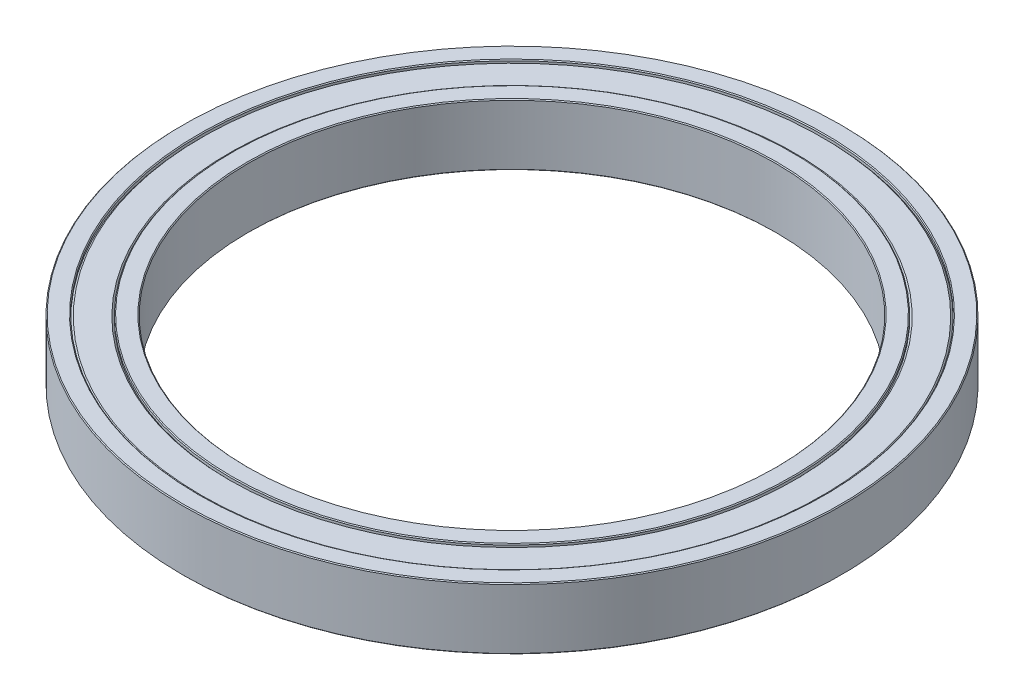
from build123d import *

# Parameters (mm, degrees)
SKETCH1_W     = 7.5
SKETCH1_H     = 7
CHAMFER1_SIZE = 0.1


with BuildPart() as part:
    # Sketch1 → Revolve1 (revolve)
    with BuildSketch(Plane(origin=(0, 0, 0), x_dir=(0, 0, -1), z_dir=(1, 0, 0))):
        with Locations((33.75, 0)):
            Rectangle(SKETCH1_W, SKETCH1_H)
    revolve(axis=Axis((0, 3.5, 0), (0, -1, 0)))

    # Sketch3 → Cut-Revolve2 (revolve, cut)
    with BuildSketch(Plane(origin=(0, 0, 0), x_dir=(0, 0, -1), z_dir=(1, 0, 0))):
        Polygon((35.3, 3.3), (35.5, 3.1), (35.5, 3.5), (32, 3.5), (32, 3.1), (32.2, 3.3), align=None)
    cut_revolve2 = revolve(axis=Axis((0, 3.5, 0), (0, -1, 0)), mode=Mode.SUBTRACT)

    # Mirror1: Cut-Revolve2 across plane
    add(cut_revolve2.mirror(Plane.ZX), mode=Mode.SUBTRACT)

    # Chamfer1
    chamfer1_edges = [part.edges().sort_by_distance(p)[0] for p in [
        (0, 3.5, 35.5),
        (0, 3.5, 32),
        (0, -3.5, 35.5),
        (0, -3.5, 32),
        (0, 3.5, 37.5),
        (0, -3.5, 37.5),
        (0, -3.5, 30),
        (0, 3.5, 30),
    ]]
    chamfer(chamfer1_edges, length=CHAMFER1_SIZE)


solid = part.part
